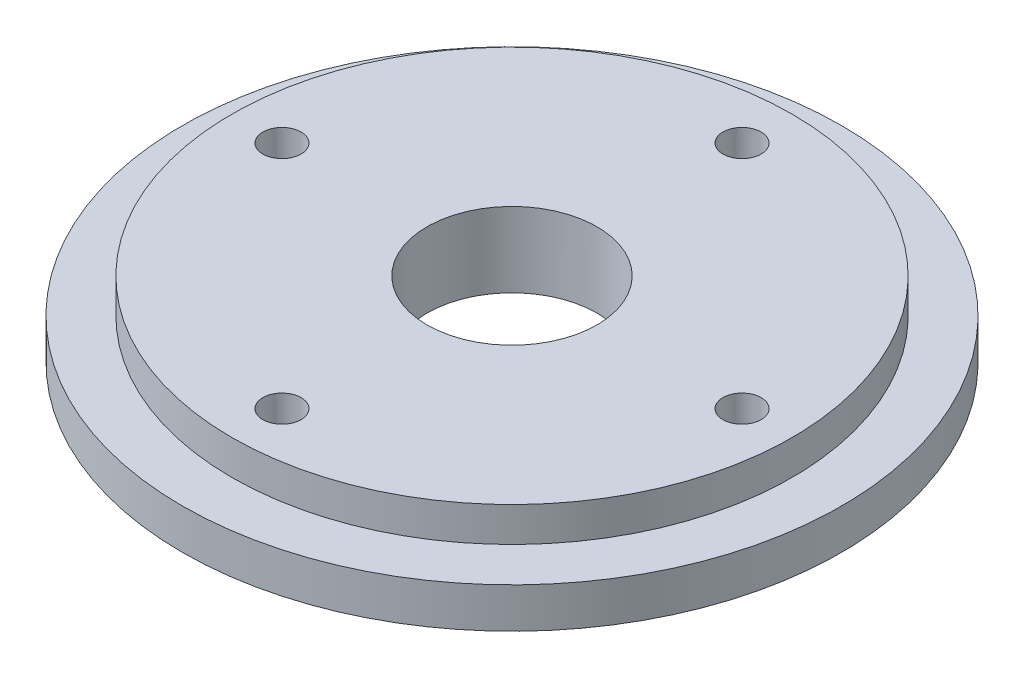
from build123d import *

# Parameters (mm, degrees)
CUT_EXTRUDE1_REACH = 13.35
SKETCH2_R          = 12.9
SKETCH2_R_2        = 2.9


with BuildPart() as part:
    # Sketch1 → Revolve1 (revolve)
    with BuildSketch(Plane.XY):
        Polygon((0, 0), (50, 0), (50, 6.1), (42.5, 6.1), (42.5, 11.35), (0, 11.35), align=None)
    revolve(axis=Axis((0, 0, 0), (0, 1, 0)))

    # Sketch2 → Cut-Extrude1 (cut, up to next)
    with BuildSketch(Plane(origin=(0, 11.35, 0), x_dir=(1, 0, 0), z_dir=(0, 1, 0)), mode=Mode.PRIVATE) as cut_extrude1_sk1:
        Circle(SKETCH2_R)
    cut_extrude1_tool1 = extrude(cut_extrude1_sk1.sketch, amount=-CUT_EXTRUDE1_REACH, mode=Mode.PRIVATE) & part.part
    add(cut_extrude1_tool1.solids().sort_by_distance((0, 11.35, 0))[0], mode=Mode.SUBTRACT)
    # Sketch2 → Cut-Extrude1 (cut, up to next)
    with BuildSketch(Plane(origin=(0, 11.35, 0), x_dir=(1, 0, 0), z_dir=(0, 1, 0)), mode=Mode.PRIVATE) as cut_extrude1_sk2:
        with Locations((0, 34.9)):
            Circle(SKETCH2_R_2)
    cut_extrude1_tool2 = extrude(cut_extrude1_sk2.sketch, amount=-CUT_EXTRUDE1_REACH, mode=Mode.PRIVATE) & part.part
    add(cut_extrude1_tool2.solids().sort_by_distance((0, 11.35, -34.9))[0], mode=Mode.SUBTRACT)
    # Sketch2 → Cut-Extrude1 (cut, up to next)
    with BuildSketch(Plane(origin=(0, 11.35, 0), x_dir=(1, 0, 0), z_dir=(0, 1, 0)), mode=Mode.PRIVATE) as cut_extrude1_sk3:
        with Locations((34.9, 0)):
            Circle(SKETCH2_R_2)
    cut_extrude1_tool3 = extrude(cut_extrude1_sk3.sketch, amount=-CUT_EXTRUDE1_REACH, mode=Mode.PRIVATE) & part.part
    add(cut_extrude1_tool3.solids().sort_by_distance((34.9, 11.35, 0))[0], mode=Mode.SUBTRACT)
    # Sketch2 → Cut-Extrude1 (cut, up to next)
    with BuildSketch(Plane(origin=(0, 11.35, 0), x_dir=(1, 0, 0), z_dir=(0, 1, 0)), mode=Mode.PRIVATE) as cut_extrude1_sk4:
        with Locations((0, -34.9)):
            Circle(SKETCH2_R_2)
    cut_extrude1_tool4 = extrude(cut_extrude1_sk4.sketch, amount=-CUT_EXTRUDE1_REACH, mode=Mode.PRIVATE) & part.part
    add(cut_extrude1_tool4.solids().sort_by_distance((0, 11.35, 34.9))[0], mode=Mode.SUBTRACT)
    # Sketch2 → Cut-Extrude1 (cut, up to next)
    with BuildSketch(Plane(origin=(0, 11.35, 0), x_dir=(1, 0, 0), z_dir=(0, 1, 0)), mode=Mode.PRIVATE) as cut_extrude1_sk5:
        with Locations((-34.9, 0)):
            Circle(SKETCH2_R_2)
    cut_extrude1_tool5 = extrude(cut_extrude1_sk5.sketch, amount=-CUT_EXTRUDE1_REACH, mode=Mode.PRIVATE) & part.part
    add(cut_extrude1_tool5.solids().sort_by_distance((-34.9, 11.35, 0))[0], mode=Mode.SUBTRACT)


solid = part.part
